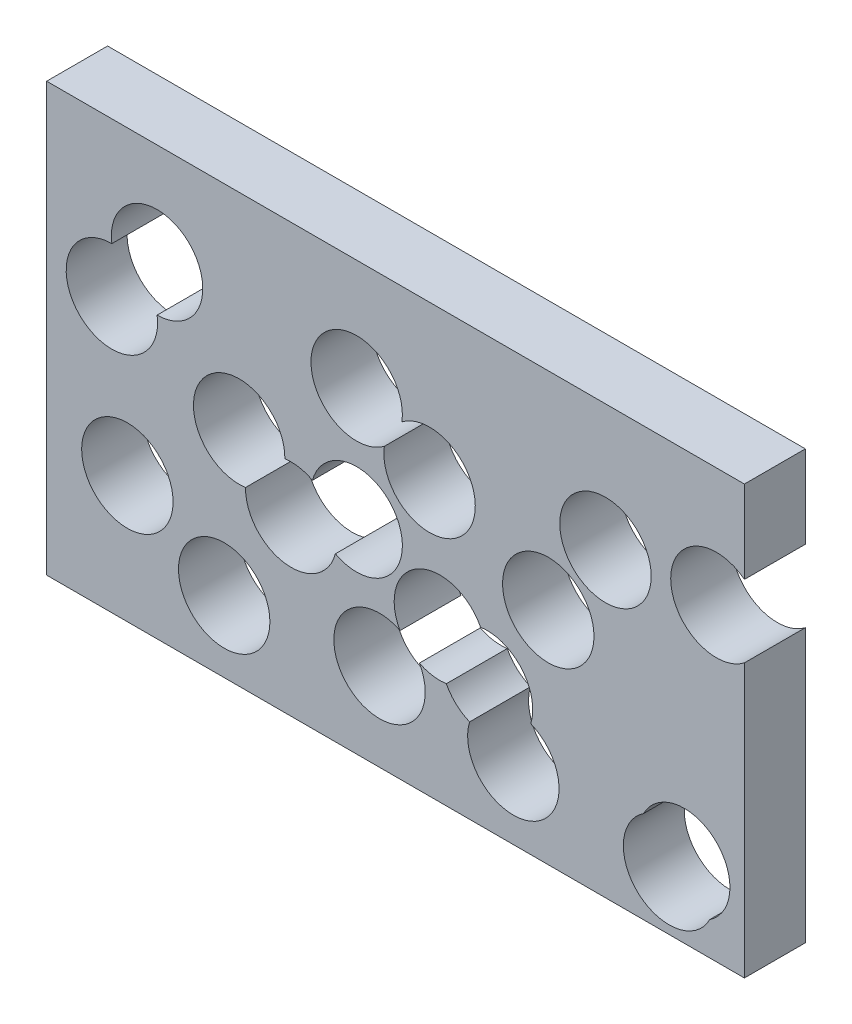
from build123d import *

# Parameters (mm, degrees)
SKICA1_W                 = 114.49904762
SKICA1_H                 = 70.201904762
P_IDAT_VYSUNUT_M1_DEPTH  = 10
ODEBRAT_VYSUNUT_M1_REACH = 69.894
SKICA2_R                 = 7.5


with BuildPart() as part:
    # Skica1 → Přidat vysunutím1 (new body)
    with BuildSketch(Plane.XY):
        Rectangle(SKICA1_W, SKICA1_H)
    extrude(amount=P_IDAT_VYSUNUT_M1_DEPTH)

    # Skica2 → Odebrat vysunutím1 (cut, up to next)
    with BuildSketch(Plane(origin=(0, 0, 0), x_dir=(-1, 0, 0), z_dir=(0, 0, -1)), mode=Mode.PRIVATE) as odebrat_vysunut_m1_sk1:
        with Locations((-44.884870965, -26.225697914)):
            Circle(SKICA2_R)
    odebrat_vysunut_m1_tool1 = extrude(odebrat_vysunut_m1_sk1.sketch, amount=-ODEBRAT_VYSUNUT_M1_REACH, mode=Mode.PRIVATE) & part.part
    odebrat_vysunut_m1 = odebrat_vysunut_m1_tool1.solids().sort_by_distance((44.884871, -26.225698, 0))[0]
    add(odebrat_vysunut_m1, mode=Mode.SUBTRACT)

    # Skica-pole1: Odebrat vysunutím1 at 17 more places
    with Locations((-10.431632, 40.559072, 0), (-47.510307, 5.535631, 0), (-91.431484, 36.089944, 0), (-19.820495, 27.327921, 0), (-29.869712, 11.905495, 0), (-39.296811, 36.089944, 0), (-51.262991, 43.110266, 0), (-73.00145, 2.810383, 0), (-62.00138, 19.782901, 0), (-70.543611, 27.327921, 0), (-51.262991, 24.48943, 0), (-37.6102, 15.915325, 0), (2.492308, 2.810383, 0), (7.770749, 41.83746, 0), (-25.552545, 2.810383, 0), (-88.893218, 11.905495, 0), (-84.014078, 44.651823, 0)):
        add(odebrat_vysunut_m1, mode=Mode.SUBTRACT)


solid = part.part
